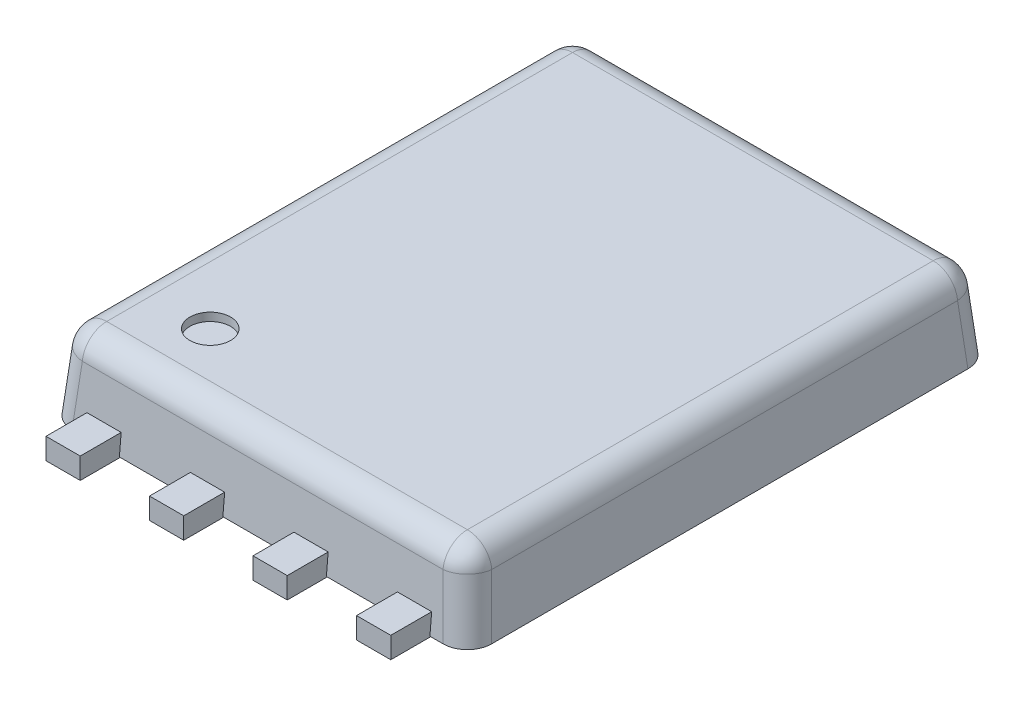
from build123d import *

# Parameters (mm, degrees)
SKETCH_1_W           = 5.15
SKETCH_1_H           = 6.44
EXTRUDE_1_DEPTH      = 1
EXTRUDE_1_TAPER      = 5
FILLET_1_R           = 0.3
SKETCH_2_R           = 0.25
CUT_EXTRUDE_1_DEPTH  = 0.1
SKETCH_3_W           = 0.42
SKETCH_3_H           = 0.91
EXTRUDE_2_DEPTH      = 0.01
EXTRUDE_2_DEPTH_BACK = 0.25


with BuildPart() as part:
    # Эскиз1 → Бобышка-Вытянуть1 (new body)
    with BuildSketch(Plane(origin=(0, 0, 0), x_dir=(1, 0, 0), z_dir=(0, 1, 0))):
        Rectangle(SKETCH_1_W, SKETCH_1_H)
    extrude(amount=EXTRUDE_1_DEPTH, taper=EXTRUDE_1_TAPER)

    # Скругление1
    fillet_1_edges = [part.edges().sort_by_distance(p)[0] for p in [
        (-2.487511336, 1, 0),
        (0, 1, 3.132511336),
        (2.487511336, 1, 0),
        (2.531255668, 0.5, 3.176255668),
        (-2.531255668, 0.5, 3.176255668),
        (-2.531255668, 0.5, -3.176255668),
        (2.531255668, 0.5, -3.176255668),
        (0, 1, -3.132511336),
    ]]
    fillet(fillet_1_edges, radius=FILLET_1_R)

    # Эскиз2 → Вырез-Вытянуть1 (cut)
    with BuildSketch(Plane(origin=(0, 1, 0), x_dir=(1, 0, 0), z_dir=(0, 1, 0))):
        with Locations((-1.5, -2.3)):
            Circle(SKETCH_2_R)
    extrude(amount=-CUT_EXTRUDE_1_DEPTH, mode=Mode.SUBTRACT)

    # Эскиз3 → Бобышка-Вытянуть2 (add, two sides)
    with BuildSketch(Plane.XZ) as extrude_2_sk:
        with Locations((-0.635, 3.245234577)):
            Rectangle(SKETCH_3_W, SKETCH_3_H)
        with Locations((1.905, 3.245234577)):
            Rectangle(SKETCH_3_W, SKETCH_3_H)
        with Locations((0.635, 3.245234577)):
            Rectangle(SKETCH_3_W, SKETCH_3_H)
        with Locations((-1.905, 3.245234577)):
            Rectangle(SKETCH_3_W, SKETCH_3_H)
    extrude(amount=EXTRUDE_2_DEPTH)
    extrude(extrude_2_sk.sketch, amount=-EXTRUDE_2_DEPTH_BACK)


solid = part.part
